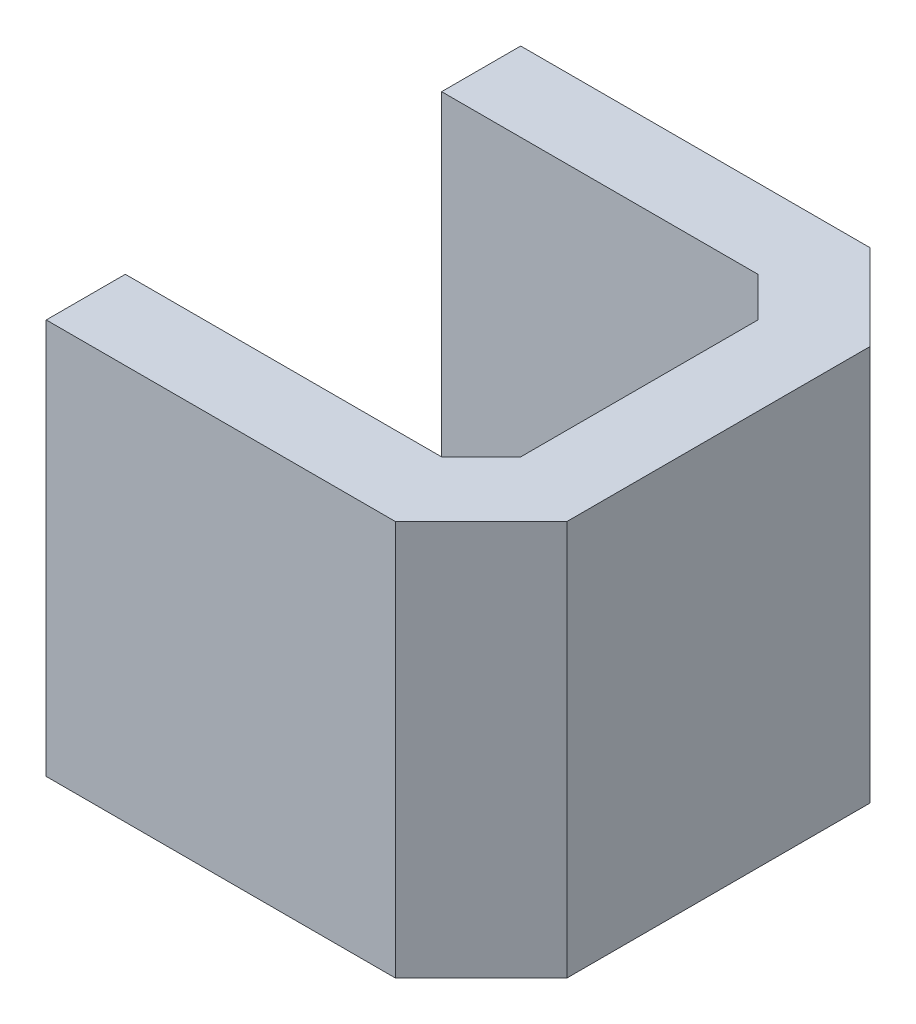
from build123d import *

# Parameters (mm, degrees)
BOSS_EXTRUDE1_DEPTH = 10


with BuildPart() as part:
    # Sketch1 → Boss-Extrude1 (new body)
    with BuildSketch(Plane(origin=(0, 0, 0), x_dir=(1, 0, 0), z_dir=(0, 1, 0))):
        Polygon((-4, 4), (4, 4), (5, 3), (5, -3), (4, -4), (-4, -4), (-4, -6), (4.828427125, -6), (7, -3.828427125), (7, 3.828427125), (4.828427125, 6), (-4, 6), align=None)
    extrude(amount=BOSS_EXTRUDE1_DEPTH)


solid = part.part
